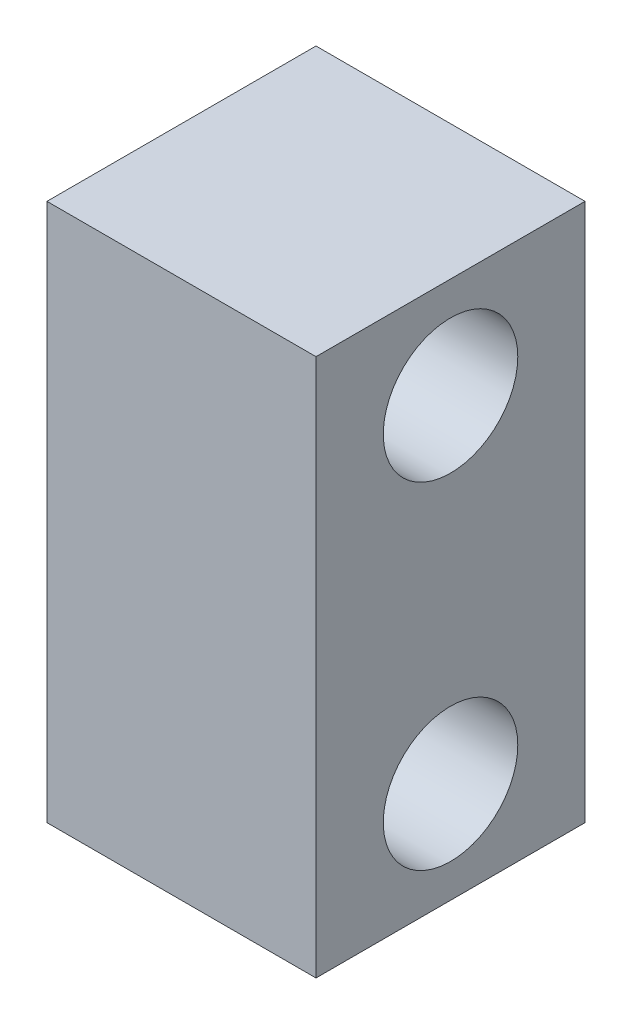
from build123d import *

# Parameters (mm, degrees)
SKETCH1_W           = 50.8
SKETCH1_H           = 101.6
BOSS_EXTRUDE1_DEPTH = 50.8
SKETCH2_R           = 12.7
CUT_EXTRUDE1_DEPTH  = 51.8


with BuildPart() as part:
    # Sketch1 → Boss-Extrude1 (new body)
    with BuildSketch(Plane.XY):
        with Locations((25.4, 50.8)):
            Rectangle(SKETCH1_W, SKETCH1_H)
    extrude(amount=BOSS_EXTRUDE1_DEPTH)

    # Sketch2 → Cut-Extrude1 (cut, through all)
    with BuildSketch(Plane(origin=(50.8, 0, 0), x_dir=(0, 0, -1), z_dir=(1, 0, 0))):
        with Locations((-25.4, 82.55)):
            Circle(SKETCH2_R)
        with Locations((-25.4, 19.05)):
            Circle(SKETCH2_R)
    extrude(amount=-CUT_EXTRUDE1_DEPTH, mode=Mode.SUBTRACT)


solid = part.part
